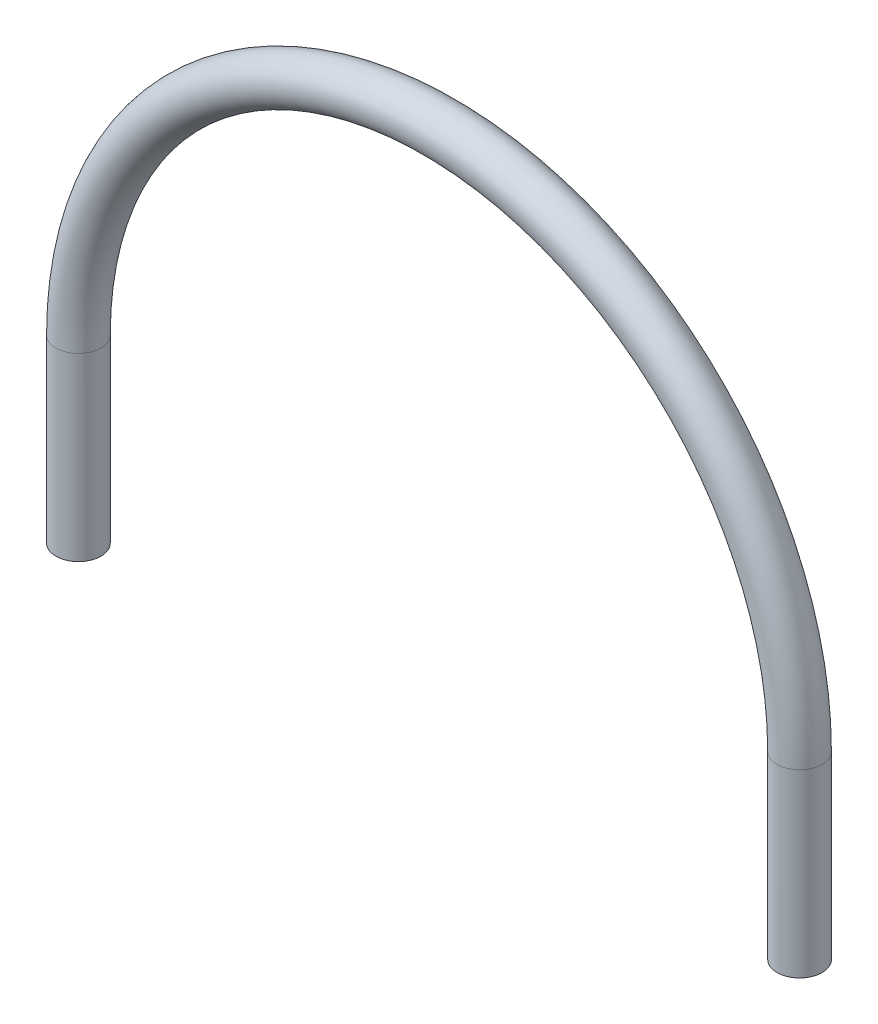
from build123d import *

# Parameters (mm, degrees)
SKETCH2_R           = 3.175
SKETCH5_R           = 3.175
BOSS_EXTRUDE1_DEPTH = 25.4


with BuildPart() as part:
    # Sweep2: sweep along a path in Sketch4
    with BuildLine(Plane.XY) as sweep2_path:
        ThreePointArc((-50.8, 0), (0, 50.8), (50.8, 0))
    # Sketch2 → Sweep2 (sweep)
    with BuildSketch(Plane(origin=(0, 0, 0), x_dir=(1, 0, 0), z_dir=(0, 1, 0))):
        with Locations((-50.8, 0)):
            Circle(SKETCH2_R)
    sweep(path=sweep2_path.line)

    # Sketch5 → Boss-Extrude1 (add)
    with BuildSketch(Plane.XZ):
        with Locations((-50.8, 0)):
            Circle(SKETCH5_R)
        with Locations((50.8, 0)):
            Circle(SKETCH5_R)
    extrude(amount=BOSS_EXTRUDE1_DEPTH)


solid = part.part
